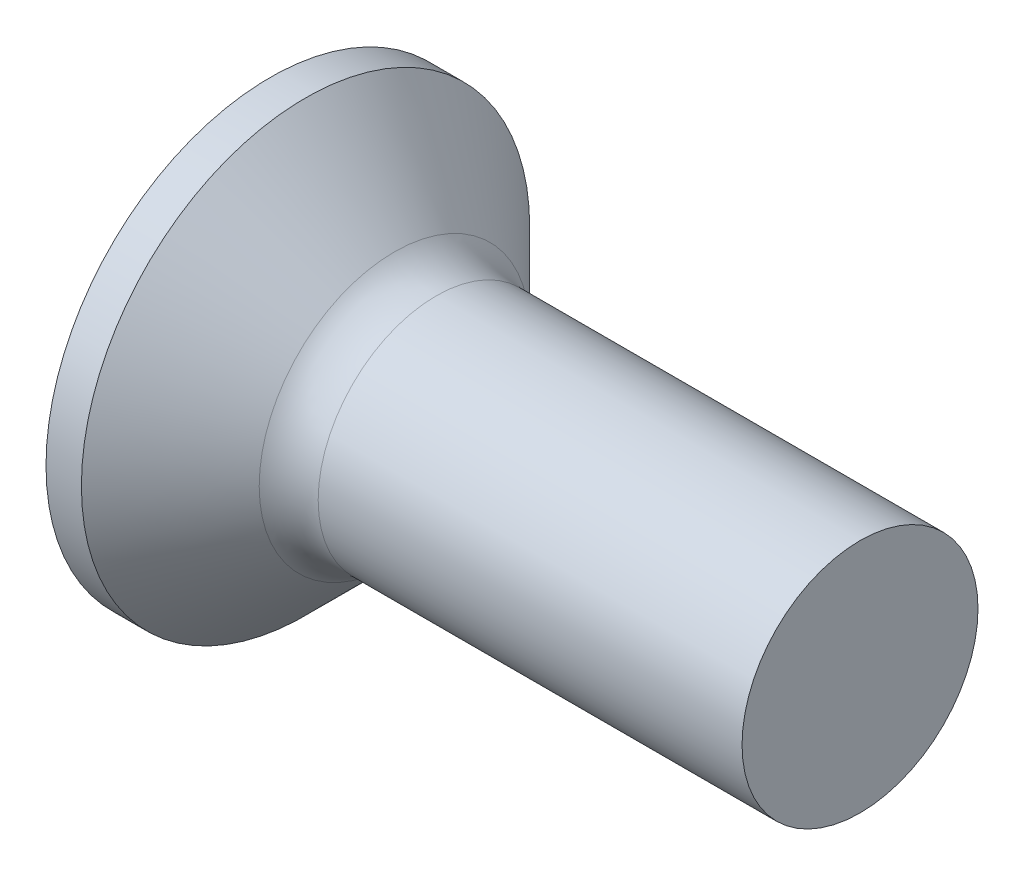
from build123d import *

# Parameters (mm, degrees)
FILLET1_R    = 0.5
SKETCH3_W    = 0.48
SKETCH3_H    = 1.9
SKETCH4_W    = 0.48
SKETCH4_H    = 0.703404182
RECPAT_COUNT = 2
RECPAT_ANGLE = 90


with BuildPart() as part:
    # BodySke → Base-Revolve (revolve)
    with BuildSketch(Plane.XY):
        Polygon((0, 0), (0, 1.9), (0.3, 1.9), (1.2, 1), (5, 1), (5, 0), align=None)
    revolve(axis=Axis((-6.35, 0, 0), (1, 0, 0)))

    # Fillet1
    fillet1_edges = [part.edges().sort_by_distance(p)[0] for p in [
        (1.2, -1, 0),
    ]]
    fillet(fillet1_edges, radius=FILLET1_R)

    # Sketch3 → Recess section 0
    with BuildSketch(Plane.ZY):
        Rectangle(SKETCH3_W, SKETCH3_H)
    # Sketch4 → Recess section 1
    with BuildSketch(Plane.ZY.offset(-1.2)):
        Rectangle(SKETCH4_W, SKETCH4_H)
    recess = loft(mode=Mode.SUBTRACT)

    # RecPat: Recess ×2 about axis
    recpat_axis = Axis((0, 0, 0), (1, 0, 0))
    for i in range(1, RECPAT_COUNT):
        add(recess.rotate(recpat_axis, i * RECPAT_ANGLE / (RECPAT_COUNT - 1)), mode=Mode.SUBTRACT)

    # RecCorSke → RecessCore (revolve, cut)
    with BuildSketch(Plane.XY):
        Polygon((0, 0), (0, 0.439412174), (1.2, 0.3555), (1.315508952, 0), align=None)
    revolve(axis=Axis((-3.175, 0, 0), (1, 0, 0)), mode=Mode.SUBTRACT)


solid = part.part
